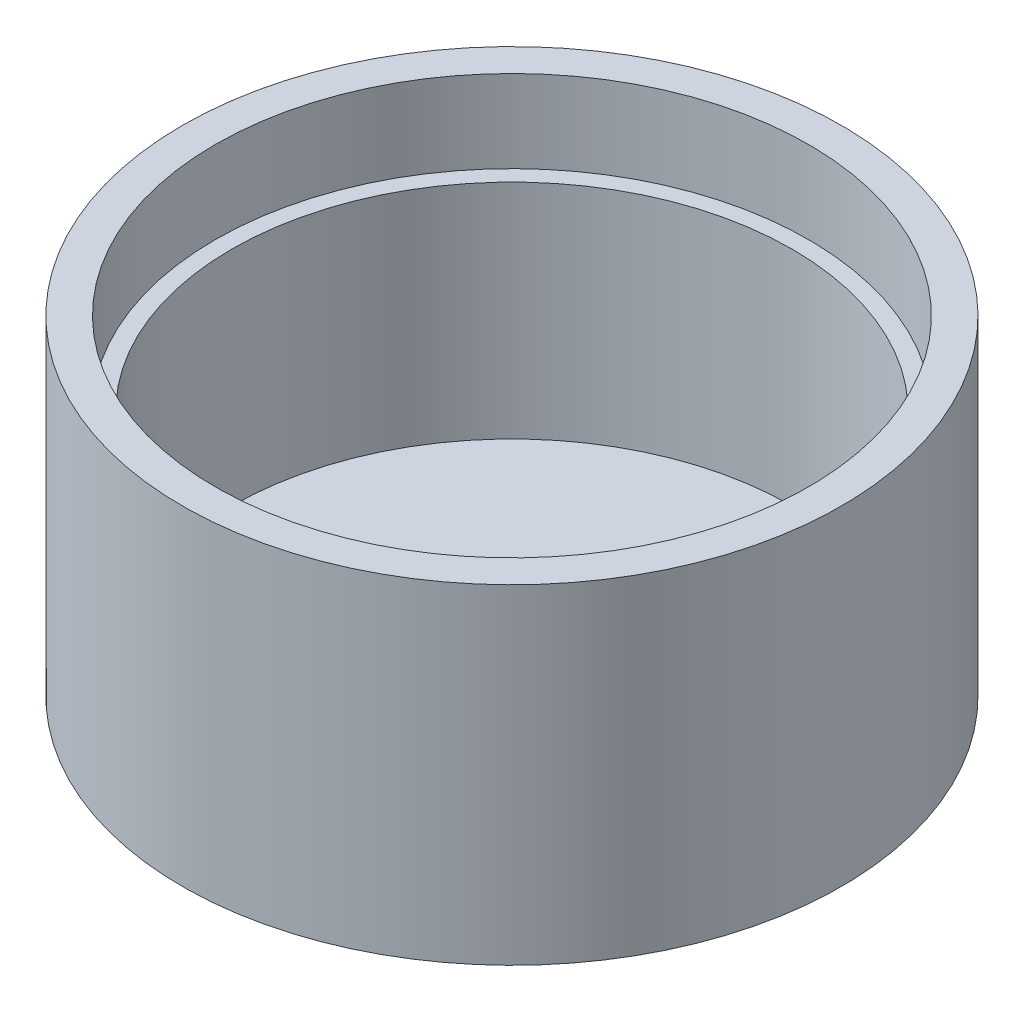
from build123d import *


with BuildPart() as part:
    # Sketch1 → Revolve1 (revolve)
    with BuildSketch(Plane.XY):
        Polygon((0, 0), (20, 0), (20, 20), (18, 20), (18, 15), (17, 15), (17, 1.5), (0, 1.5), align=None)
    revolve(axis=Axis((0, 1.5, 0), (0, -1, 0)))


solid = part.part
